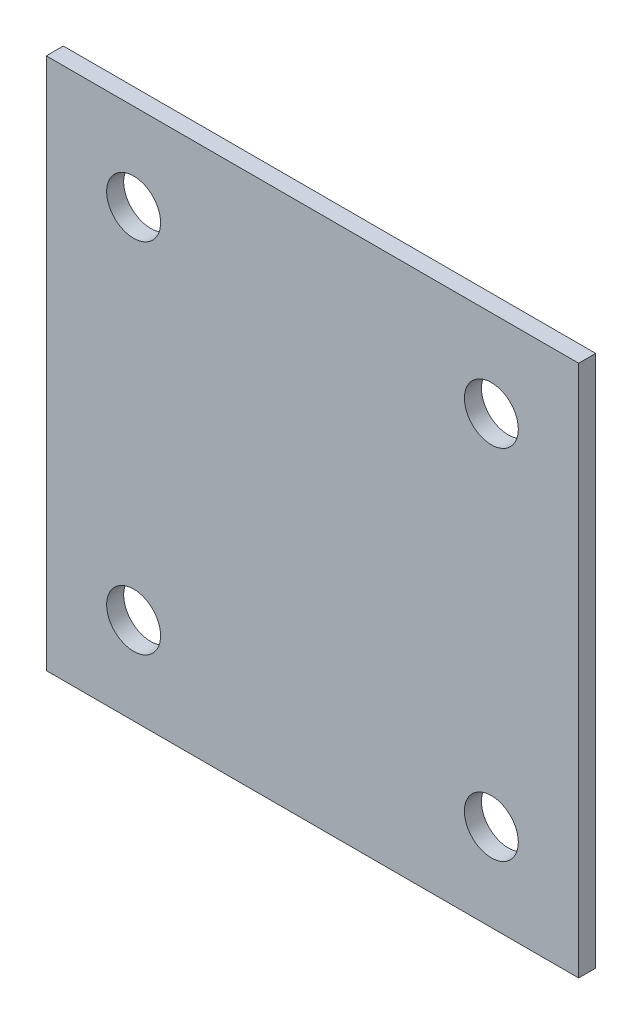
from build123d import *

# Parameters (mm, degrees)
SKETCH1_W           = 47.625
SKETCH1_H           = 47.625
SKETCH1_R           = 2.413
BOSS_EXTRUDE1_DEPTH = 1.524


with BuildPart() as part:
    # Sketch1 → Boss-Extrude1 (new body)
    with BuildSketch(Plane.XY):
        Rectangle(SKETCH1_W, SKETCH1_H)
        with Locations((-16, 16)):
            Circle(SKETCH1_R, mode=Mode.SUBTRACT)
        with Locations((16, 16)):
            Circle(SKETCH1_R, mode=Mode.SUBTRACT)
        with Locations((-16, -16)):
            Circle(SKETCH1_R, mode=Mode.SUBTRACT)
        with Locations((16, -16)):
            Circle(SKETCH1_R, mode=Mode.SUBTRACT)
    extrude(amount=-BOSS_EXTRUDE1_DEPTH)


solid = part.part
